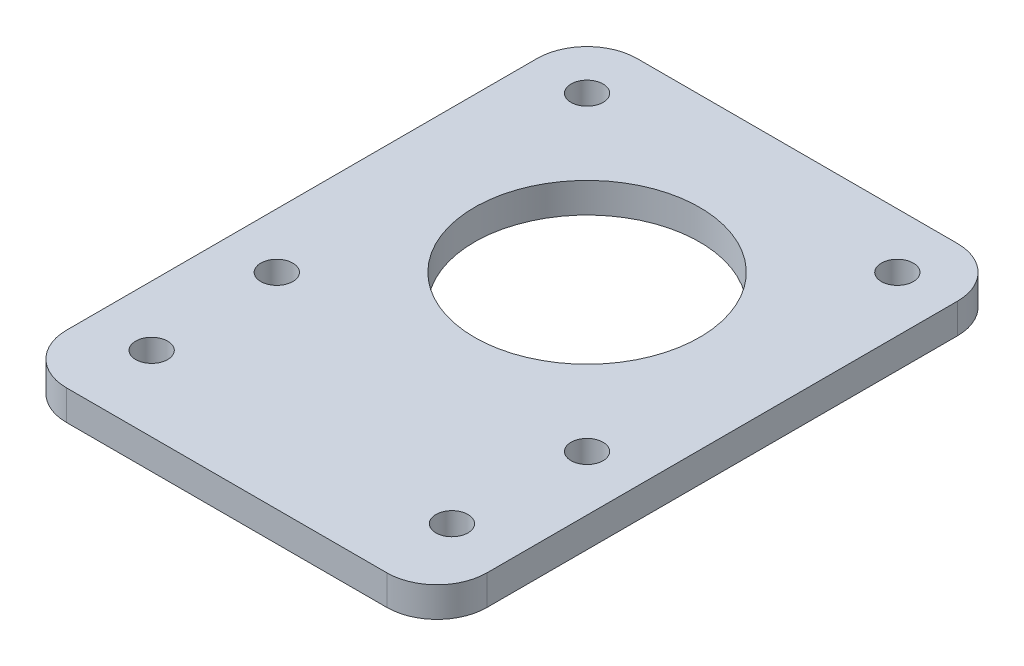
from build123d import *

# Parameters (mm, degrees)
SKETCH1_W           = 42
SKETCH1_H           = 57
SKETCH1_R           = 1.6
SKETCH1_R_2         = 11.25
BOSS_EXTRUDE1_DEPTH = 3
FILLET1_R           = 5


with BuildPart() as part:
    # Sketch1 → Boss-Extrude1 (new body)
    with BuildSketch(Plane(origin=(0, 0, 0), x_dir=(1, 0, 0), z_dir=(0, 1, 0))):
        with Locations((21, 28.5)):
            Rectangle(SKETCH1_W, SKETCH1_H)
        with Locations((36.5, 51.5)):
            Circle(SKETCH1_R, mode=Mode.SUBTRACT)
        with Locations((5.5, 51.5)):
            Circle(SKETCH1_R, mode=Mode.SUBTRACT)
        with Locations((5.5, 20.5)):
            Circle(SKETCH1_R, mode=Mode.SUBTRACT)
        with Locations((36.5, 20.5)):
            Circle(SKETCH1_R, mode=Mode.SUBTRACT)
        with Locations((6, 7.5)):
            Circle(SKETCH1_R, mode=Mode.SUBTRACT)
        with Locations((36, 7.5)):
            Circle(SKETCH1_R, mode=Mode.SUBTRACT)
        with Locations((21, 36)):
            Circle(SKETCH1_R_2, mode=Mode.SUBTRACT)
    extrude(amount=BOSS_EXTRUDE1_DEPTH)

    # Fillet1
    fillet1_edges = [part.edges().sort_by_distance(p)[0] for p in [
        (0, 1.5, -57),
        (42, 1.5, -57),
        (42, 1.5, 0),
        (0, 1.5, 0),
    ]]
    fillet(fillet1_edges, radius=FILLET1_R)


solid = part.part
